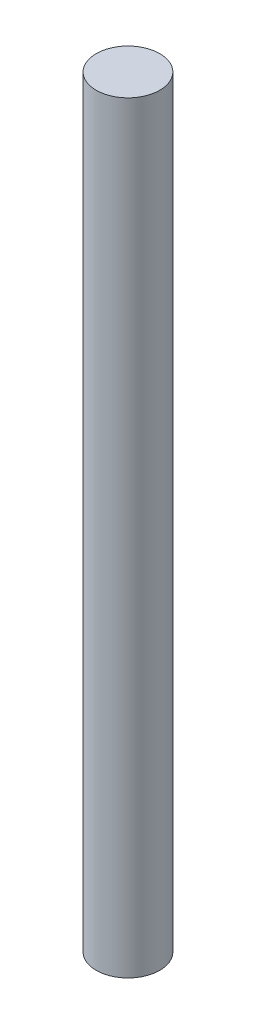
from build123d import *

# Parameters (mm, degrees)
SKETCH1_R           = 0.396875
BOSS_EXTRUDE1_DEPTH = 9.525


with BuildPart() as part:
    # Sketch1 → Boss-Extrude1 (new body)
    with BuildSketch(Plane(origin=(0, 0, 0), x_dir=(1, 0, 0), z_dir=(0, 1, 0))):
        Circle(SKETCH1_R)
    extrude(amount=BOSS_EXTRUDE1_DEPTH)


solid = part.part
